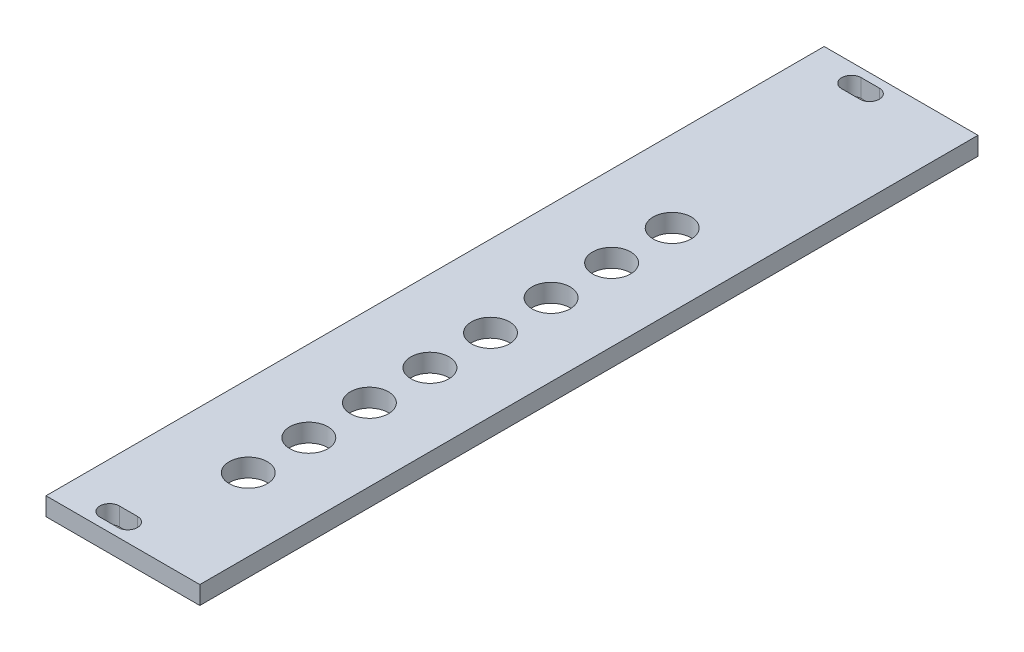
from build123d import *

# Parameters (mm, degrees)
SKIZZE1_W                       = 25.4
SKIZZE1_H                       = 128.5
AUFSATZ_LINEAR_AUSTRAGEN1_DEPTH = 3
SCHNITT_LINEAR_AUSTRAGEN4_DEPTH = 4
SKIZZE3_R                       = 3.15
SCHNITT_LINEAR_AUSTRAGEN6_DEPTH = 4


with BuildPart() as part:
    # Skizze1 → Aufsatz-Linear austragen1 (new body)
    with BuildSketch(Plane(origin=(0, 0, 0), x_dir=(1, 0, 0), z_dir=(0, 1, 0))):
        Rectangle(SKIZZE1_W, SKIZZE1_H)
    extrude(amount=AUFSATZ_LINEAR_AUSTRAGEN1_DEPTH)

    # Skizze2 → Schnitt-Linear austragen4 (cut, through all)
    with BuildSketch(Plane(origin=(0, 0, 0), x_dir=(1, 0, 0), z_dir=(0, 1, 0))):
        with BuildLine():
            Line((-5.2, 62.85), (-2.2, 62.85))
            ThreePointArc((-2.2, 62.85), (-0.6, 61.25), (-2.2, 59.65))
            Line((-2.2, 59.65), (-5.2, 59.65))
            ThreePointArc((-5.2, 59.65), (-6.8, 61.25), (-5.2, 62.85))
        make_face()
        with BuildLine():
            Line((-5.2, -59.65), (-2.2, -59.65))
            ThreePointArc((-2.2, -59.65), (-0.6, -61.25), (-2.2, -62.85))
            Line((-2.2, -62.85), (-5.2, -62.85))
            ThreePointArc((-5.2, -62.85), (-6.8, -61.25), (-5.2, -59.65))
        make_face()
    extrude(amount=SCHNITT_LINEAR_AUSTRAGEN4_DEPTH, mode=Mode.SUBTRACT)

    # Skizze3 → Schnitt-Linear austragen6 (cut, through all)
    with BuildSketch(Plane(origin=(0, 0, 0), x_dir=(1, 0, 0), z_dir=(0, 1, 0))):
        with Locations((0.7, -44.25)):
            Circle(SKIZZE3_R)
        with Locations((0.7, -34.25)):
            Circle(SKIZZE3_R)
        with Locations((0.7, -24.25)):
            Circle(SKIZZE3_R)
        with Locations((0.7, -14.25)):
            Circle(SKIZZE3_R)
        with Locations((0.7, -4.25)):
            Circle(SKIZZE3_R)
        with Locations((0.7, 5.75)):
            Circle(SKIZZE3_R)
        with Locations((0.7, 15.75)):
            Circle(SKIZZE3_R)
        with Locations((0.7, 25.75)):
            Circle(SKIZZE3_R)
    extrude(amount=SCHNITT_LINEAR_AUSTRAGEN6_DEPTH, mode=Mode.SUBTRACT)


solid = part.part
